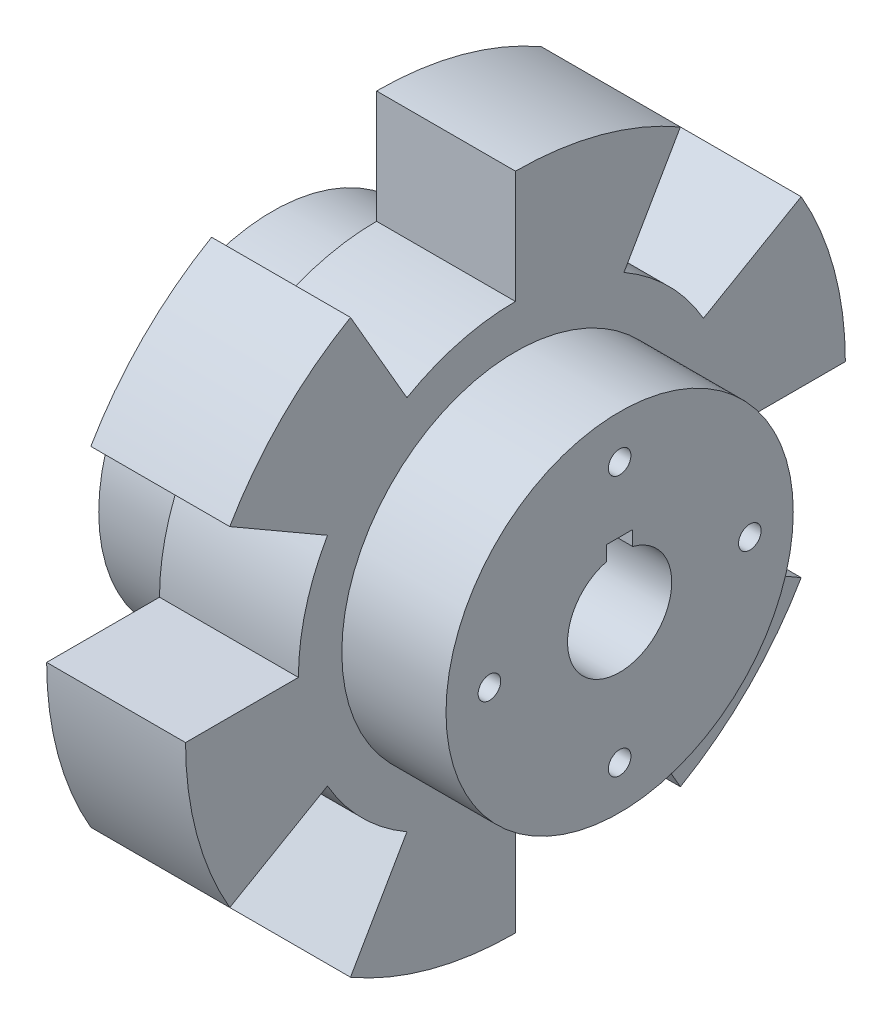
from build123d import *

# Parameters (mm, degrees)
ESBO_O2_R             = 6
CORTE_EXTRUS_O1_DEPTH = 41
CORTE_EXTRUS_O7_DEPTH = 41
CORTE_EXTRUS_O8_DEPTH = 29
ESBO_O10_R            = 1.3
CORTE_EXTRUS_O9_DEPTH = 41


with BuildPart() as part:
    # Esboço1 → Revolução1 (revolve)
    with BuildSketch(Plane.XY):
        Polygon((0, 0), (12, 0), (12, 18), (28, 18), (28, 0), (40, 0), (40, -20), (0, -20), align=None)
    revolve(axis=Axis((0, -20, 0), (1, 0, 0)))

    # Esboço2 → Corte-extrusão1 (cut, through all)
    with BuildSketch(Plane.ZY):
        with Locations((0, -20)):
            Circle(ESBO_O2_R)
    extrude(amount=-CORTE_EXTRUS_O1_DEPTH, mode=Mode.SUBTRACT)

    # Esboço8 → Corte-extrusão7 (cut, through all)
    with BuildSketch(Plane.ZY):
        Polygon((0, -12.5), (1.5, -12.5), (1.5, -14.653499006), (-1.5, -14.653499006), (-1.5, -12.5), align=None)
    extrude(amount=-CORTE_EXTRUS_O7_DEPTH, mode=Mode.SUBTRACT)

    # Esboço9 → Corte-extrusão8 (cut, through all)
    with BuildSketch(Plane.ZY.offset(-12)):
        with BuildLine():
            Line((0, -58), (0, -45))
            ThreePointArc((0, -45), (-6.470476128, -44.148145657), (-12.5, -41.650635095))
            Line((-12.5, -41.650635095), (-19, -52.908965344))
            ThreePointArc((-19, -52.908965344), (-9.835123714, -56.705181399), (0, -58))
        make_face()
        with BuildLine():
            Line((19, 12.908965344), (12.5, 1.650635095))
            ThreePointArc((12.5, 1.650635095), (6.470476128, 4.148145657), (0, 5))
            Line((0, 5), (0, 18))
            ThreePointArc((0, 18), (9.835123714, 16.705181399), (19, 12.908965344))
        make_face()
        with BuildLine():
            Line((-19, 12.908965344), (-12.5, 1.650635095))
            ThreePointArc((-12.5, 1.650635095), (-17.67766953, -2.32233047), (-21.650635095, -7.5))
            Line((-21.650635095, -7.5), (-32.908965344, -1))
            ThreePointArc((-32.908965344, -1), (-26.870057685, 6.870057685), (-19, 12.908965344))
        make_face()
        with BuildLine():
            Line((32.908965344, -1), (21.650635095, -7.5))
            ThreePointArc((21.650635095, -7.5), (24.148145657, -13.529523872), (25, -20))
            Line((25, -20), (38, -20))
            ThreePointArc((38, -20), (36.705181399, -10.164876286), (32.908965344, -1))
        make_face()
        with BuildLine():
            Line((19, -52.908965344), (12.5, -41.650635095))
            ThreePointArc((12.5, -41.650635095), (17.67766953, -37.67766953), (21.650635095, -32.5))
            Line((21.650635095, -32.5), (32.908965344, -39))
            ThreePointArc((32.908965344, -39), (26.870057685, -46.870057685), (19, -52.908965344))
        make_face()
        with BuildLine():
            Line((-38, -20), (-25, -20))
            ThreePointArc((-25, -20), (-24.148145657, -26.470476128), (-21.650635095, -32.5))
            Line((-21.650635095, -32.5), (-32.908965344, -39))
            ThreePointArc((-32.908965344, -39), (-36.705181399, -29.835123714), (-38, -20))
        make_face()
    extrude(amount=-CORTE_EXTRUS_O8_DEPTH, mode=Mode.SUBTRACT)

    # Esboço10 → Corte-extrusão9 (cut, through all)
    with BuildSketch(Plane.ZY):
        with Locations((0, -5.003986953)):
            Circle(ESBO_O10_R)
        with Locations((14.996013047, -20)):
            Circle(ESBO_O10_R)
        with Locations((0, -34.996013047)):
            Circle(ESBO_O10_R)
        with Locations((-14.996013047, -20)):
            Circle(ESBO_O10_R)
    extrude(amount=-CORTE_EXTRUS_O9_DEPTH, mode=Mode.SUBTRACT)


solid = part.part
